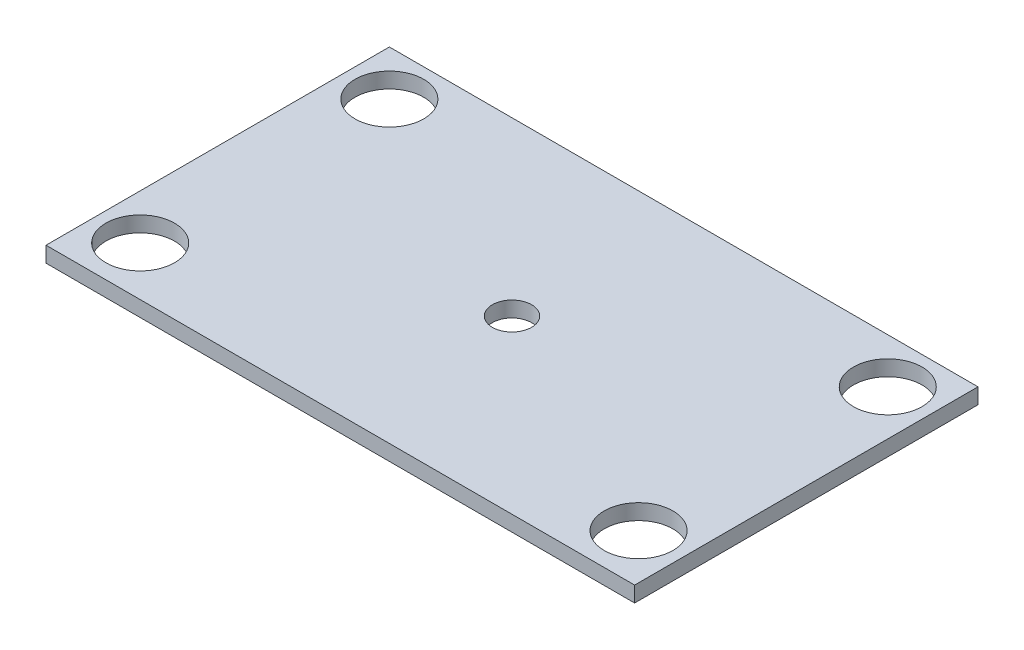
from build123d import *

# Parameters (mm, degrees)
SKETCH1_W           = 60
SKETCH1_H           = 35
SKETCH1_R           = 3.5
SKETCH1_R_2         = 2
BOSS_EXTRUDE1_DEPTH = 1.5875


with BuildPart() as part:
    # Sketch1 → Boss-Extrude1 (new body)
    with BuildSketch(Plane(origin=(0, 0, 0), x_dir=(1, 0, 0), z_dir=(0, 1, 0))):
        with Locations((30, 17.5)):
            Rectangle(SKETCH1_W, SKETCH1_H)
        with Locations((4.6, 30.4)):
            Circle(SKETCH1_R, mode=Mode.SUBTRACT)
        with Locations((55.4, 30.4)):
            Circle(SKETCH1_R, mode=Mode.SUBTRACT)
        with Locations((4.6, 5)):
            Circle(SKETCH1_R, mode=Mode.SUBTRACT)
        with Locations((55.4, 5)):
            Circle(SKETCH1_R, mode=Mode.SUBTRACT)
        with Locations((30, 17.5)):
            Circle(SKETCH1_R_2, mode=Mode.SUBTRACT)
    extrude(amount=BOSS_EXTRUDE1_DEPTH)


solid = part.part
